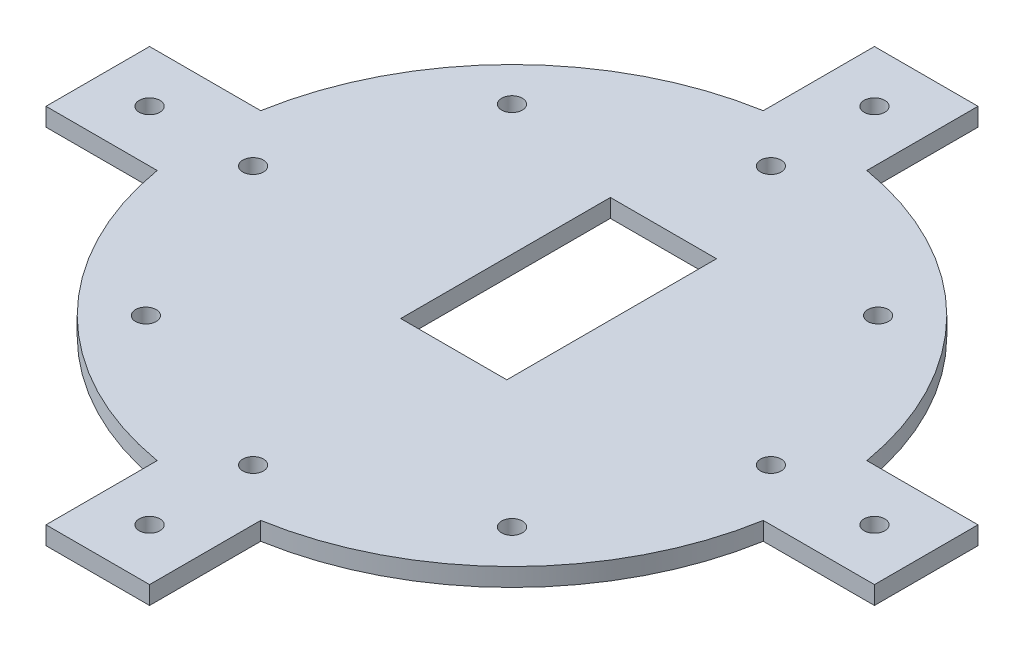
from build123d import *

# Parameters (mm, degrees)
SALIENTE_EXTRUIR1_DEPTH = 3.5
CROQUIS2_R              = 2
CORTAR_EXTRUIR1_DEPTH   = 3.5
MATRIZC1_COUNT          = 8
CORTAR_EXTRUIR2_REACH   = 5.5
CROQUIS3_W              = 20.5
CROQUIS3_H              = 40.5
CORTAR_EXTRUIR3_REACH   = 5.5
CROQUIS4_R              = 2


with BuildPart() as part:
    # Croquis1 → Saliente-Extruir1 (new body)
    with BuildSketch(Plane(origin=(0, 0, 0), x_dir=(1, 0, 0), z_dir=(0, 1, 0))):
        with BuildLine():
            Line((-10, -58.530413525), (-10, -80))
            Line((-10, -80), (10, -80))
            Line((10, -80), (10, -58.530413525))
            ThreePointArc((10, -58.530413525), (41.986958138, -41.986958138), (58.530413525, -10))
            Line((58.530413525, -10), (80, -10))
            Line((80, -10), (80, 10))
            Line((80, 10), (58.530413525, 10))
            ThreePointArc((58.530413525, 10), (41.986958138, 41.986958138), (10, 58.530413525))
            Line((10, 58.530413525), (10, 80))
            Line((10, 80), (-10, 80))
            Line((-10, 80), (-10, 58.530413525))
            ThreePointArc((-10, 58.530413525), (-41.986958138, 41.986958138), (-58.530413525, 10))
            Line((-58.530413525, 10), (-80, 10))
            Line((-80, 10), (-80, -10))
            Line((-80, -10), (-58.530413525, -10))
            ThreePointArc((-58.530413525, -10), (-41.986958138, -41.986958138), (-10, -58.530413525))
        make_face()
    extrude(amount=SALIENTE_EXTRUIR1_DEPTH)

    # Croquis2 → Cortar-Extruir1 (cut)
    with BuildSketch(Plane(origin=(0, 3.5, 0), x_dir=(1, 0, 0), z_dir=(0, 1, 0))):
        with Locations((0, 50)):
            Circle(CROQUIS2_R)
    cortar_extruir1 = extrude(amount=-CORTAR_EXTRUIR1_DEPTH, mode=Mode.SUBTRACT)

    # MatrizC1: Cortar-Extruir1 ×8 about axis
    matrizc1_axis = Axis((0, 0, 0), (0, 1, 0))
    for i in range(1, MATRIZC1_COUNT):
        add(cortar_extruir1.rotate(matrizc1_axis, i * 360 / MATRIZC1_COUNT), mode=Mode.SUBTRACT)

    # Croquis3 → Cortar-Extruir2 (cut, up to next)
    with BuildSketch(Plane(origin=(0, 3.5, 0), x_dir=(1, 0, 0), z_dir=(0, 1, 0)), mode=Mode.PRIVATE) as cortar_extruir2_sk1:
        with Locations((0, 9)):
            Rectangle(CROQUIS3_W, CROQUIS3_H)
    cortar_extruir2_tool1 = extrude(cortar_extruir2_sk1.sketch, amount=-CORTAR_EXTRUIR2_REACH, mode=Mode.PRIVATE) & part.part
    add(cortar_extruir2_tool1.solids().sort_by_distance((0, 3.5, -9))[0], mode=Mode.SUBTRACT)

    # Croquis4 → Cortar-Extruir3 (cut, up to next)
    with BuildSketch(Plane(origin=(0, 3.5, 0), x_dir=(1, 0, 0), z_dir=(0, 1, 0)), mode=Mode.PRIVATE) as cortar_extruir3_sk1:
        with Locations((0, 70)):
            Circle(CROQUIS4_R)
    cortar_extruir3_tool1 = extrude(cortar_extruir3_sk1.sketch, amount=-CORTAR_EXTRUIR3_REACH, mode=Mode.PRIVATE) & part.part
    add(cortar_extruir3_tool1.solids().sort_by_distance((0, 3.5, -70))[0], mode=Mode.SUBTRACT)
    # Croquis4 → Cortar-Extruir3 (cut, up to next)
    with BuildSketch(Plane(origin=(0, 3.5, 0), x_dir=(1, 0, 0), z_dir=(0, 1, 0)), mode=Mode.PRIVATE) as cortar_extruir3_sk2:
        with Locations((70, 0)):
            Circle(CROQUIS4_R)
    cortar_extruir3_tool2 = extrude(cortar_extruir3_sk2.sketch, amount=-CORTAR_EXTRUIR3_REACH, mode=Mode.PRIVATE) & part.part
    add(cortar_extruir3_tool2.solids().sort_by_distance((70, 3.5, 0))[0], mode=Mode.SUBTRACT)
    # Croquis4 → Cortar-Extruir3 (cut, up to next)
    with BuildSketch(Plane(origin=(0, 3.5, 0), x_dir=(1, 0, 0), z_dir=(0, 1, 0)), mode=Mode.PRIVATE) as cortar_extruir3_sk3:
        with Locations((0, -70)):
            Circle(CROQUIS4_R)
    cortar_extruir3_tool3 = extrude(cortar_extruir3_sk3.sketch, amount=-CORTAR_EXTRUIR3_REACH, mode=Mode.PRIVATE) & part.part
    add(cortar_extruir3_tool3.solids().sort_by_distance((0, 3.5, 70))[0], mode=Mode.SUBTRACT)
    # Croquis4 → Cortar-Extruir3 (cut, up to next)
    with BuildSketch(Plane(origin=(0, 3.5, 0), x_dir=(1, 0, 0), z_dir=(0, 1, 0)), mode=Mode.PRIVATE) as cortar_extruir3_sk4:
        with Locations((-70, 0)):
            Circle(CROQUIS4_R)
    cortar_extruir3_tool4 = extrude(cortar_extruir3_sk4.sketch, amount=-CORTAR_EXTRUIR3_REACH, mode=Mode.PRIVATE) & part.part
    add(cortar_extruir3_tool4.solids().sort_by_distance((-70, 3.5, 0))[0], mode=Mode.SUBTRACT)


solid = part.part
